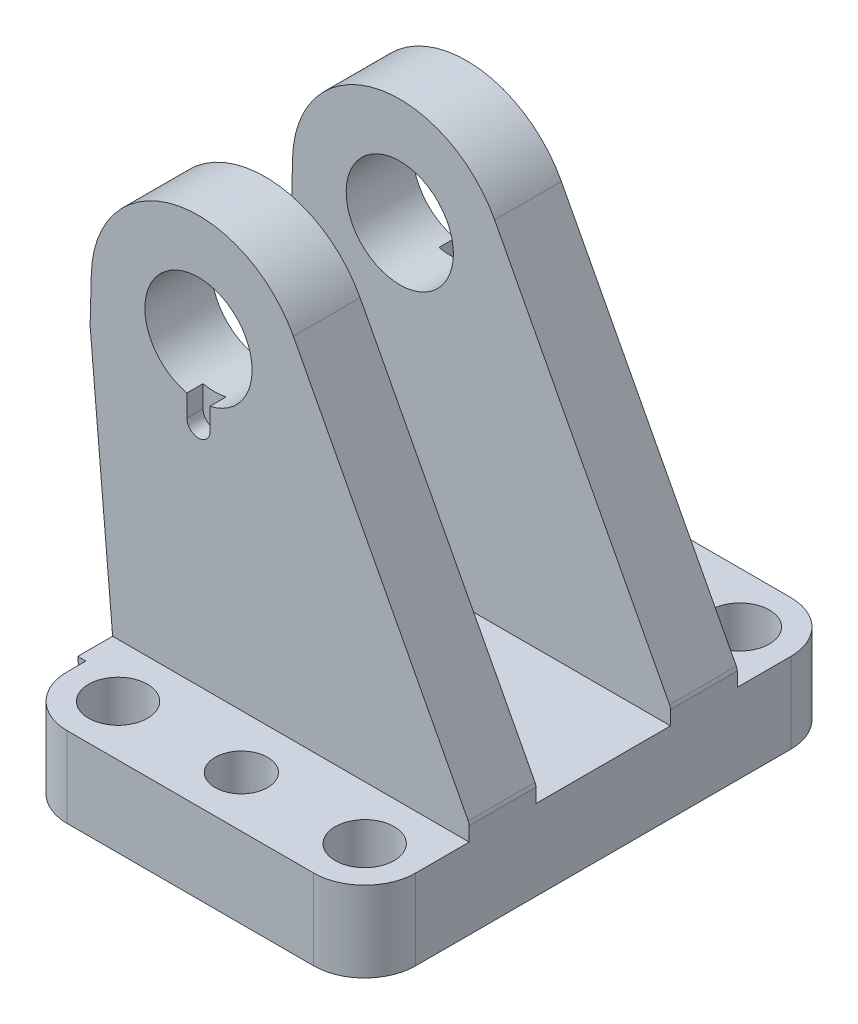
from build123d import *

# Parameters (mm, degrees)
SKETCH1_R                = 5.5
SKETCH1_R_2              = 4.9
BOSS_EXTRUDE1_DEPTH      = 15
BOSS_EXTRUDE2_DEPTH      = 31.5
BOSS_EXTRUDE2_DEPTH_BACK = 31.5
SKETCH3_R                = 10
BOSS_EXTRUDE3_DEPTH      = 12.45
SKETCH4_R                = 10
BOSS_EXTRUDE4_DEPTH      = 12.45
CUT_EXTRUDE1_DEPTH       = 3
CUT_EXTRUDE1_DEPTH_BACK  = 3
CUT_EXTRUDE2_DEPTH       = 3
CUT_EXTRUDE2_DEPTH_BACK  = 3


with BuildPart() as part:
    # Sketch1 → Boss-Extrude1 (new body)
    with BuildSketch(Plane(origin=(0, 0, 0), x_dir=(1, 0, 0), z_dir=(0, 1, 0))):
        with BuildLine():
            Line((-23, -44.5), (23, -44.5))
            ThreePointArc((23, -44.5), (29.717514421, -41.717514421), (32.5, -35))
            Line((32.5, -35), (32.5, 35))
            ThreePointArc((32.5, 35), (29.717514421, 41.717514421), (23, 44.5))
            Line((23, 44.5), (-23, 44.5))
            ThreePointArc((-23, 44.5), (-29.717514421, 41.717514421), (-32.5, 35))
            Line((-32.5, 35), (-32.5, -35))
            ThreePointArc((-32.5, -35), (-29.717514421, -41.717514421), (-23, -44.5))
        make_face()
        with Locations((23, 35)):
            Circle(SKETCH1_R, mode=Mode.SUBTRACT)
        with Locations((23, -35)):
            Circle(SKETCH1_R, mode=Mode.SUBTRACT)
        with Locations((0, 35)):
            Circle(SKETCH1_R_2, mode=Mode.SUBTRACT)
        with Locations((0, -35)):
            Circle(SKETCH1_R_2, mode=Mode.SUBTRACT)
        with Locations((-23, 35)):
            Circle(SKETCH1_R, mode=Mode.SUBTRACT)
        with Locations((-23, -35)):
            Circle(SKETCH1_R, mode=Mode.SUBTRACT)
    extrude(amount=BOSS_EXTRUDE1_DEPTH)

    # Sketch2 → Boss-Extrude2 (add, two sides)
    with BuildSketch(Plane.XY) as boss_extrude2_sk:
        Polygon((-34.012329953, 15), (-32.7, 0), (-27.7, 0), (-27.7, 15), align=None)
    extrude(amount=BOSS_EXTRUDE2_DEPTH)
    extrude(boss_extrude2_sk.sketch, amount=-BOSS_EXTRUDE2_DEPTH_BACK)

    # Sketch3 → Boss-Extrude3 (add)
    with BuildSketch(Plane.XY.offset(25)):
        with BuildLine():
            Line((-38.215293381, 63.040091813), (-32.7, 0))
            Line((-32.7, 0), (32.5, 0))
            Line((32.5, 0), (32.5, 17.62932037))
            ThreePointArc((32.5, 17.62932037), (32.456195267, 17.989174985), (32.327339541, 18.32801182))
            Line((32.327339541, 18.32801182), (-0.302139449, 80.315885997))
            ThreePointArc((-0.302139449, 80.315885997), (-22.543503711, 90.47707817), (-37.9931465, 71.523538966))
            Line((-37.9931465, 71.523538966), (-38.215293381, 63.040091813))
        make_face()
        with Locations((-18, 71)):
            Circle(SKETCH3_R, mode=Mode.SUBTRACT)
    extrude(amount=-BOSS_EXTRUDE3_DEPTH)

    # Sketch4 → Boss-Extrude4 (add)
    with BuildSketch(Plane.XY.offset(-25)):
        with BuildLine():
            Line((-38.215293381, 63.040091813), (-32.7, 0))
            Line((-32.7, 0), (32.5, 0))
            Line((32.5, 0), (32.5, 17.62932037))
            ThreePointArc((32.5, 17.62932037), (32.456195267, 17.989174985), (32.327339541, 18.32801182))
            Line((32.327339541, 18.32801182), (-0.302139449, 80.315885997))
            ThreePointArc((-0.302139449, 80.315885997), (-22.543503711, 90.47707817), (-37.9931465, 71.523538966))
            Line((-37.9931465, 71.523538966), (-38.215293381, 63.040091813))
        make_face()
        with Locations((-18, 71)):
            Circle(SKETCH4_R, mode=Mode.SUBTRACT)
    extrude(amount=BOSS_EXTRUDE4_DEPTH)

    # Sketch5 → Cut-Extrude1 (cut, two sides)
    with BuildSketch(Plane.XY.offset(25)) as cut_extrude1_sk:
        with BuildLine():
            Line((-15.85, 57.15), (-15.85, 71))
            Line((-15.85, 71), (-20.15, 71))
            Line((-20.15, 71), (-20.15, 57.15))
            ThreePointArc((-20.15, 57.15), (-18, 55), (-15.85, 57.15))
        make_face()
    extrude(amount=CUT_EXTRUDE1_DEPTH, mode=Mode.SUBTRACT)
    extrude(cut_extrude1_sk.sketch, amount=-CUT_EXTRUDE1_DEPTH_BACK, mode=Mode.SUBTRACT)

    # Sketch6 → Cut-Extrude2 (cut, two sides)
    with BuildSketch(Plane.XY.offset(-25)) as cut_extrude2_sk:
        with BuildLine():
            Line((-15.85, 57.15), (-15.85, 71))
            Line((-15.85, 71), (-20.15, 71))
            Line((-20.15, 71), (-20.15, 57.15))
            ThreePointArc((-20.15, 57.15), (-18, 55), (-15.85, 57.15))
        make_face()
    extrude(amount=CUT_EXTRUDE2_DEPTH, mode=Mode.SUBTRACT)
    extrude(cut_extrude2_sk.sketch, amount=-CUT_EXTRUDE2_DEPTH_BACK, mode=Mode.SUBTRACT)


solid = part.part
